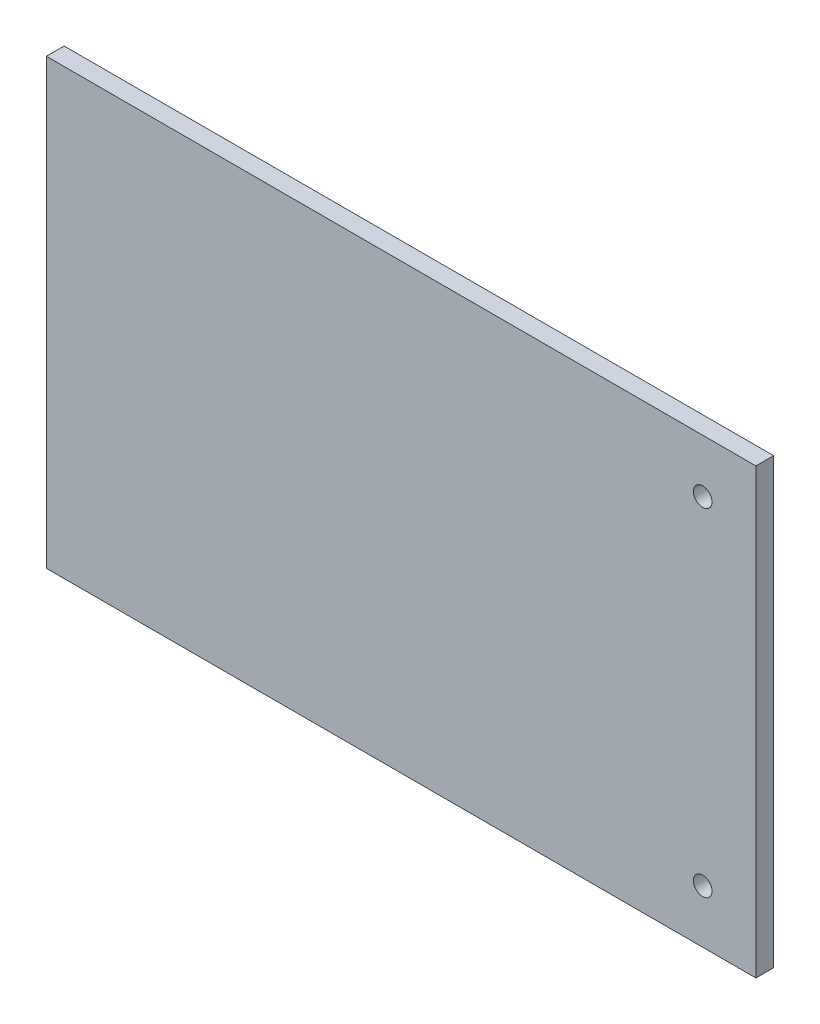
from build123d import *

# Parameters (mm, degrees)
SKIZZE1_W                          = 400
SKIZZE1_H                          = 250
AUFSATZ_LINEAR_AUSTRAGEN1_DEPTH    = 10
F_10_5_10_5_DURCHMESSER_BOHRUNG1_D = 10.5


with BuildPart() as part:
    # Skizze1 → Aufsatz-Linear austragen1 (new body)
    with BuildSketch(Plane.XY):
        Rectangle(SKIZZE1_W, SKIZZE1_H)
    extrude(amount=AUFSATZ_LINEAR_AUSTRAGEN1_DEPTH)

    # Ø10.5 (10.5) Durchmesser Bohrung1 (through all)
    with Locations(Plane.XY.offset(10)):
        with Locations((170, 95), (170, -95)):
            Hole(F_10_5_10_5_DURCHMESSER_BOHRUNG1_D / 2)


solid = part.part
